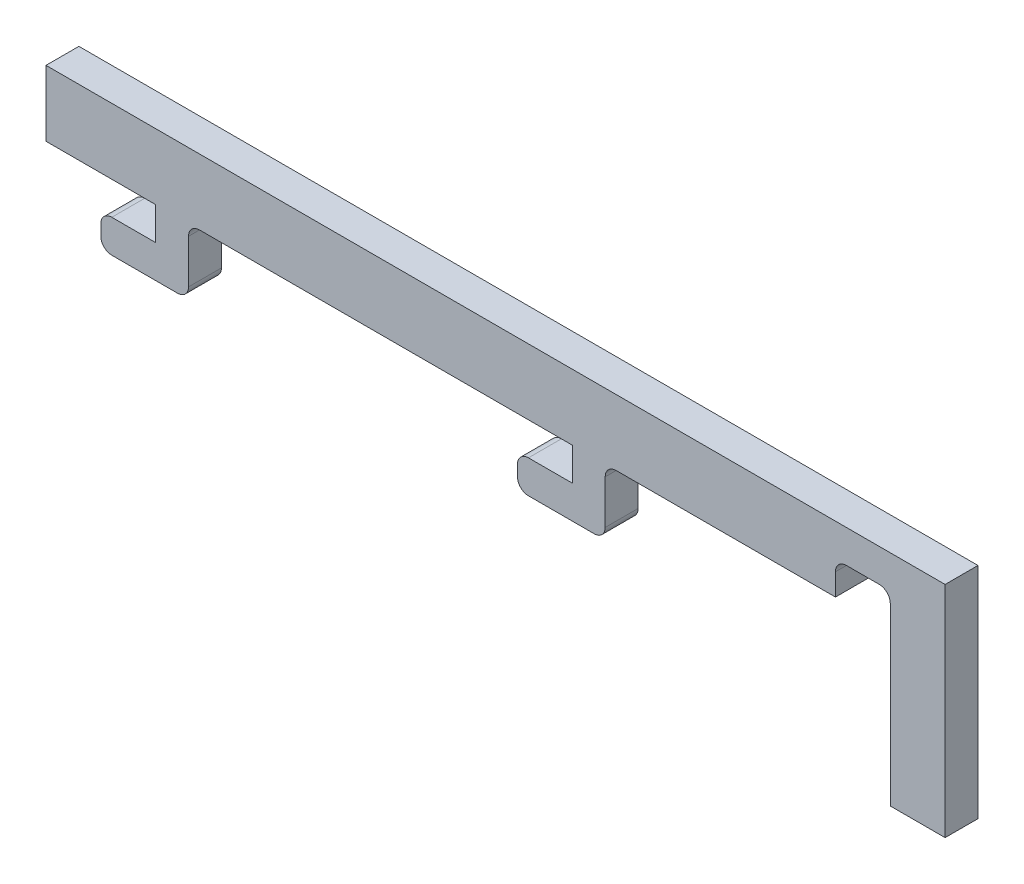
from build123d import *

# Parameters (mm, degrees)
BOSS_EXTRUDE1_DEPTH = 3


with BuildPart() as part:
    # Sketch3 → Boss-Extrude1 (new body)
    with BuildSketch(Plane.XY):
        with BuildLine():
            Line((29.616597331, 4), (-41.383402669, 4))
            Line((-41.383402669, 4), (-41.383402669, 1))
            Line((-41.383402669, 1), (-41.383402669, -2))
            Line((-41.383402669, -2), (-31.383402669, -2))
            Line((-31.383402669, -2), (-31.383402669, -5))
            Line((-31.383402669, -5), (-35.383402669, -5))
            ThreePointArc((-35.383402669, -5), (-36.09050945, -5.292893219), (-36.383402669, -6))
            Line((-36.383402669, -6), (-36.383402669, -7))
            ThreePointArc((-36.383402669, -7), (-36.09050945, -7.707106781), (-35.383402669, -8))
            Line((-35.383402669, -8), (-29.383402669, -8))
            ThreePointArc((-29.383402669, -8), (-28.676295888, -7.707106781), (-28.383402669, -7))
            Line((-28.383402669, -7), (-28.383402669, -3))
            ThreePointArc((-28.383402669, -3), (-28.09050945, -2.292893219), (-27.383402669, -2))
            Line((-27.383402669, -2), (6.616597331, -2))
            Line((6.616597331, -2), (6.616597331, -5))
            Line((6.616597331, -5), (2.616597331, -5))
            ThreePointArc((2.616597331, -5), (1.90949055, -5.292893219), (1.616597331, -6))
            Line((1.616597331, -6), (1.616597331, -7))
            ThreePointArc((1.616597331, -7), (1.90949055, -7.707106781), (2.616597331, -8))
            Line((2.616597331, -8), (8.616597331, -8))
            ThreePointArc((8.616597331, -8), (9.323704112, -7.707106781), (9.616597331, -7))
            Line((9.616597331, -7), (9.616597331, -3))
            ThreePointArc((9.616597331, -3), (9.90949055, -2.292893219), (10.616597331, -2))
            Line((10.616597331, -2), (30.616597331, -2))
            Line((30.616597331, -2), (30.616597331, 0))
            ThreePointArc((30.616597331, 0), (30.90949055, 0.707106781), (31.616597331, 1))
            Line((31.616597331, 1), (34.616597331, 1))
            ThreePointArc((34.616597331, 1), (35.323704112, 0.707106781), (35.616597331, 0))
            Line((35.616597331, 0), (35.616597331, -16))
            Line((35.616597331, -16), (40.616597331, -16))
            Line((40.616597331, -16), (40.616597331, 4))
            Line((40.616597331, 4), (35.616597331, 4))
            Line((35.616597331, 4), (29.616597331, 4))
        make_face()
    extrude(amount=BOSS_EXTRUDE1_DEPTH)


solid = part.part
